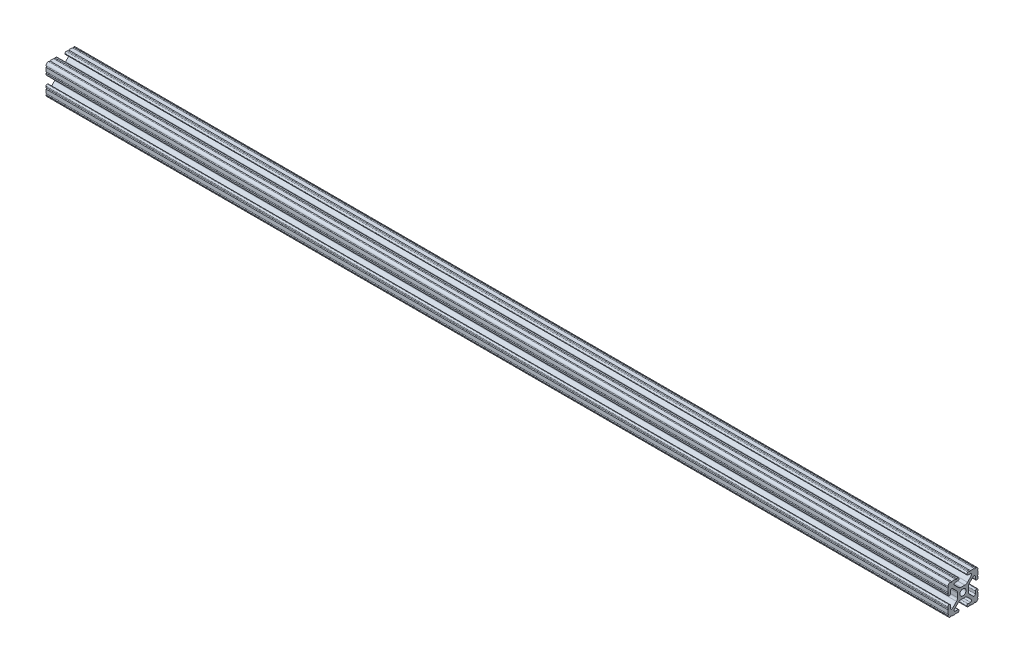
from build123d import *

# Parameters (mm, degrees)
SKETCH11_R                     = 2.6035
EXTRUSION_1010_PROFILE_1_DEPTH = 760


with BuildPart() as part:
    # Sketch11 → Extrusion 1010 PROFILE(1) (new body)
    with BuildSketch(Plane.YZ):
        with BuildLine():
            Line((-1.709253557, -4.4958), (1.709253557, -4.4958))
            ThreePointArc((1.709253557, -4.4958), (2.922935876, -4.736928798), (3.95226937, -5.423689619))
            Line((3.95226937, -5.423689619), (7.179652728, -8.645192207))
            ThreePointArc((7.179652728, -8.645192207), (7.414733441, -9.822812921), (6.41641086, -10.4902))
            Line((6.41641086, -10.4902), (4.28752, -10.4902))
            ThreePointArc((4.28752, -10.4902), (3.545750844, -10.797450844), (3.2385, -11.53922))
            Line((3.2385, -11.53922), (3.2385, -11.65098))
            ThreePointArc((3.2385, -11.65098), (3.545750844, -12.392749156), (4.28752, -12.7))
            Line((4.28752, -12.7), (5.3171344, -12.7))
            ThreePointArc((5.3171344, -12.7), (5.8251344, -12.192), (6.3331344, -12.7))
            Line((6.3331344, -12.7), (9.5504, -12.7))
            ThreePointArc((9.5504, -12.7), (10.058323491, -12.192000006), (10.566399977, -12.699846982))
            ThreePointArc((10.566399977, -12.699846982), (12.082522516, -12.082522516), (12.699846982, -10.566399977))
            ThreePointArc((12.699846982, -10.566399977), (12.192000006, -10.058323491), (12.7, -9.5504))
            Line((12.7, -9.5504), (12.7, -6.3330836))
            ThreePointArc((12.7, -6.3330836), (12.192, -5.8250836), (12.7, -5.3170836))
            Line((12.7, -5.3170836), (12.7, -4.287470133))
            ThreePointArc((12.7, -4.287470133), (12.392749156, -3.545700977), (11.65098, -3.238450133))
            Line((11.65098, -3.238450133), (11.53922, -3.238450133))
            ThreePointArc((11.53922, -3.238450133), (10.797450844, -3.545700977), (10.4902, -4.287470133))
            Line((10.4902, -4.287470133), (10.4902, -6.402089023))
            ThreePointArc((10.4902, -6.402089023), (9.856394933, -7.351113629), (8.736962546, -7.129240479))
            Line((8.736962546, -7.129240479), (5.440484187, -3.838768792))
            ThreePointArc((5.440484187, -3.838768792), (4.75073678, -2.808015636), (4.5085, -1.591658411))
            Line((4.5085, -1.591658411), (4.5085, 1.591658411))
            ThreePointArc((4.5085, 1.591658411), (4.75073678, 2.808015636), (5.440484187, 3.838768792))
            Line((5.440484187, 3.838768792), (8.736962546, 7.129240479))
            ThreePointArc((8.736962546, 7.129240479), (9.856394933, 7.351113629), (10.4902, 6.402089023))
            Line((10.4902, 6.402089023), (10.4902, 4.287470133))
            ThreePointArc((10.4902, 4.287470133), (10.797450844, 3.545700977), (11.53922, 3.238450133))
            Line((11.53922, 3.238450133), (11.65098, 3.238450133))
            ThreePointArc((11.65098, 3.238450133), (12.392749156, 3.545700977), (12.7, 4.287470133))
            Line((12.7, 4.287470133), (12.7, 5.3171344))
            ThreePointArc((12.7, 5.3171344), (12.192, 5.8251344), (12.7, 6.3331344))
            Line((12.7, 6.3331344), (12.7, 9.5504))
            ThreePointArc((12.7, 9.5504), (12.192000006, 10.058323491), (12.699846982, 10.566399977))
            ThreePointArc((12.699846982, 10.566399977), (12.082522516, 12.082522516), (10.566399977, 12.699846982))
            ThreePointArc((10.566399977, 12.699846982), (10.058323491, 12.192000006), (9.5504, 12.7))
            Line((9.5504, 12.7), (6.3330836, 12.7))
            ThreePointArc((6.3330836, 12.7), (5.8250836, 12.192), (5.3170836, 12.7))
            Line((5.3170836, 12.7), (4.2874692, 12.7))
            ThreePointArc((4.2874692, 12.7), (3.545700044, 12.392749156), (3.2384492, 11.65098))
            Line((3.2384492, 11.65098), (3.2384492, 11.53922))
            ThreePointArc((3.2384492, 11.53922), (3.545700044, 10.797450844), (4.2874692, 10.4902))
            Line((4.2874692, 10.4902), (6.476774195, 10.4902))
            ThreePointArc((6.476774195, 10.4902), (7.43216212, 9.851515102), (7.207191475, 8.724540082))
            Line((7.207191475, 8.724540082), (3.900315394, 5.423689619))
            ThreePointArc((3.900315394, 5.423689619), (2.8709819, 4.736928798), (1.657299581, 4.4958))
            Line((1.657299581, 4.4958), (-1.657299581, 4.4958))
            ThreePointArc((-1.657299581, 4.4958), (-2.8709819, 4.736928798), (-3.900315394, 5.423689619))
            Line((-3.900315394, 5.423689619), (-7.207191475, 8.724540082))
            ThreePointArc((-7.207191475, 8.724540082), (-7.43216212, 9.851515102), (-6.476774195, 10.4902))
            Line((-6.476774195, 10.4902), (-4.2874692, 10.4902))
            ThreePointArc((-4.2874692, 10.4902), (-3.545700044, 10.797450844), (-3.2384492, 11.53922))
            Line((-3.2384492, 11.53922), (-3.2384492, 11.65098))
            ThreePointArc((-3.2384492, 11.65098), (-3.545700044, 12.392749156), (-4.2874692, 12.7))
            Line((-4.2874692, 12.7), (-5.3170836, 12.7))
            ThreePointArc((-5.3170836, 12.7), (-5.8250836, 12.192), (-6.3330836, 12.7))
            Line((-6.3330836, 12.7), (-9.5504, 12.7))
            ThreePointArc((-9.5504, 12.7), (-10.058323491, 12.192000006), (-10.566399977, 12.699846982))
            ThreePointArc((-10.566399977, 12.699846982), (-12.082522516, 12.082522516), (-12.699846982, 10.566399977))
            ThreePointArc((-12.699846982, 10.566399977), (-12.192000006, 10.058323491), (-12.7, 9.5504))
            Line((-12.7, 9.5504), (-12.7, 6.3331344))
            ThreePointArc((-12.7, 6.3331344), (-12.192, 5.8251344), (-12.7, 5.3171344))
            Line((-12.7, 5.3171344), (-12.7, 4.287470133))
            ThreePointArc((-12.7, 4.287470133), (-12.392749156, 3.545700977), (-11.65098, 3.238450133))
            Line((-11.65098, 3.238450133), (-11.53922, 3.238450133))
            ThreePointArc((-11.53922, 3.238450133), (-10.797450844, 3.545700977), (-10.4902, 4.287470133))
            Line((-10.4902, 4.287470133), (-10.4902, 6.402089023))
            ThreePointArc((-10.4902, 6.402089023), (-9.856394933, 7.351113629), (-8.736962546, 7.129240479))
            Line((-8.736962546, 7.129240479), (-5.440484187, 3.838768792))
            ThreePointArc((-5.440484187, 3.838768792), (-4.75073678, 2.808015636), (-4.5085, 1.591658411))
            Line((-4.5085, 1.591658411), (-4.5085, -1.591658411))
            ThreePointArc((-4.5085, -1.591658411), (-4.75073678, -2.808015636), (-5.440484187, -3.838768792))
            Line((-5.440484187, -3.838768792), (-8.736962546, -7.129240479))
            ThreePointArc((-8.736962546, -7.129240479), (-9.856394933, -7.351113629), (-10.4902, -6.402089023))
            Line((-10.4902, -6.402089023), (-10.4902, -4.287470133))
            ThreePointArc((-10.4902, -4.287470133), (-10.797450844, -3.545700977), (-11.53922, -3.238450133))
            Line((-11.53922, -3.238450133), (-11.65098, -3.238450133))
            ThreePointArc((-11.65098, -3.238450133), (-12.392749156, -3.545700977), (-12.7, -4.287470133))
            Line((-12.7, -4.287470133), (-12.7, -5.3170836))
            ThreePointArc((-12.7, -5.3170836), (-12.192, -5.8250836), (-12.7, -6.3330836))
            Line((-12.7, -6.3330836), (-12.7, -9.5504))
            ThreePointArc((-12.7, -9.5504), (-12.192000006, -10.058323491), (-12.699846982, -10.566399977))
            ThreePointArc((-12.699846982, -10.566399977), (-12.082522516, -12.082522516), (-10.566399977, -12.699846982))
            ThreePointArc((-10.566399977, -12.699846982), (-10.058323491, -12.192000006), (-9.5504, -12.7))
            Line((-9.5504, -12.7), (-6.3331344, -12.7))
            ThreePointArc((-6.3331344, -12.7), (-5.8251344, -12.192), (-5.3171344, -12.7))
            Line((-5.3171344, -12.7), (-4.28752, -12.7))
            ThreePointArc((-4.28752, -12.7), (-3.545750844, -12.392749156), (-3.2385, -11.65098))
            Line((-3.2385, -11.65098), (-3.2385, -11.53922))
            ThreePointArc((-3.2385, -11.53922), (-3.545750844, -10.797450844), (-4.28752, -10.4902))
            Line((-4.28752, -10.4902), (-6.41641086, -10.4902))
            ThreePointArc((-6.41641086, -10.4902), (-7.414733441, -9.822812921), (-7.179652728, -8.645192207))
            Line((-7.179652728, -8.645192207), (-3.95226937, -5.423689619))
            ThreePointArc((-3.95226937, -5.423689619), (-2.922935876, -4.736928798), (-1.709253557, -4.4958))
        make_face()
        Circle(SKETCH11_R, mode=Mode.SUBTRACT)
    extrude(amount=EXTRUSION_1010_PROFILE_1_DEPTH)


solid = part.part
